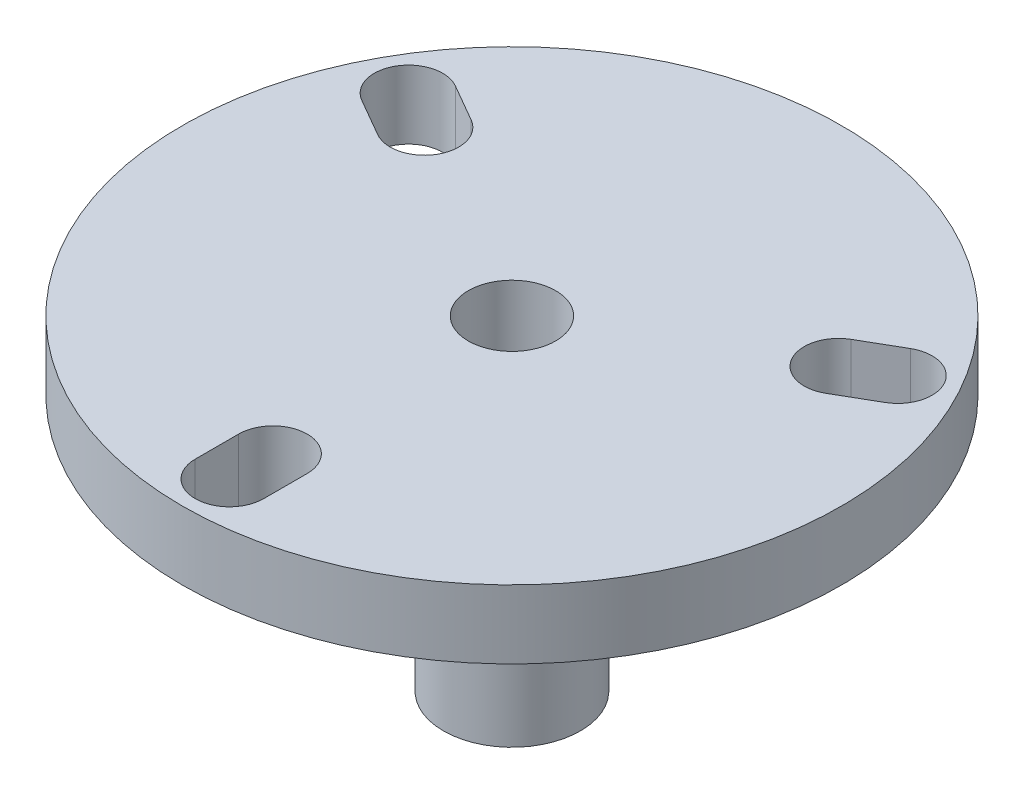
from build123d import *

# Parameters (mm, degrees)
SKETCH1_R           = 19.25
SKETCH1_R_2         = 4
BOSS_EXTRUDE1_DEPTH = 4
SKETCH1_4_R         = 4
BOSS_EXTRUDE2_DEPTH = 19


with BuildPart() as part:
    # Sketch1 → Boss-Extrude1 (new body)
    with BuildSketch(Plane(origin=(0, 0, 0), x_dir=(1, 0, 0), z_dir=(0, 1, 0))):
        Circle(SKETCH1_R)
        with BuildLine():
            Line((-13.089714637, 5.247949192), (-15.289419162, 6.517949192))
            ThreePointArc((-15.289419162, 6.517949192), (-16.02146997, 9.25), (-13.289419162, 9.982050808))
            Line((-13.289419162, 9.982050808), (-11.089714637, 8.712050808))
            ThreePointArc((-11.089714637, 8.712050808), (-10.357663829, 5.98), (-13.089714637, 5.247949192))
        make_face(mode=Mode.SUBTRACT)
        with BuildLine():
            Line((11.089714637, 8.712050808), (13.289419162, 9.982050808))
            ThreePointArc((13.289419162, 9.982050808), (16.02146997, 9.25), (15.289419162, 6.517949192))
            Line((15.289419162, 6.517949192), (13.089714637, 5.247949192))
            ThreePointArc((13.089714637, 5.247949192), (10.357663829, 5.98), (11.089714637, 8.712050808))
        make_face(mode=Mode.SUBTRACT)
        with BuildLine():
            Line((2, -13.96), (2, -16.5))
            ThreePointArc((2, -16.5), (0, -18.5), (-2, -16.5))
            Line((-2, -16.5), (-2, -13.96))
            ThreePointArc((-2, -13.96), (0, -11.96), (2, -13.96))
        make_face(mode=Mode.SUBTRACT)
        Circle(SKETCH1_R_2, mode=Mode.SUBTRACT)
    extrude(amount=-BOSS_EXTRUDE1_DEPTH)

    # Sketch1_4 → Boss-Extrude2 (add)
    with BuildSketch(Plane(origin=(0, 0, 0), x_dir=(1, 0, 0), z_dir=(0, 1, 0))):
        Circle(SKETCH1_4_R)
    extrude(amount=-BOSS_EXTRUDE2_DEPTH)

    # Sketch2 → Cut-Revolve4 (revolve, cut)
    with BuildSketch(Plane(origin=(0, 0, 0), x_dir=(0, 0, -1), z_dir=(1, 0, 0))):
        Polygon((0, -19), (0.8, -19), (0.8, -17), (1, 0), (0, 0), align=None)
    revolve(axis=Axis((0, 0, 0), (0, -1, 0)), mode=Mode.SUBTRACT)

    # Sketch5 → Cut-Revolve8 (revolve, cut)
    with BuildSketch(Plane.XY):
        Polygon((0, -7), (-2.55, -5.527756814), (-2.55, 0), (0, 0), align=None)
    revolve(axis=Axis((0, 0, 0), (0, -1, 0)), mode=Mode.SUBTRACT)


solid = part.part
